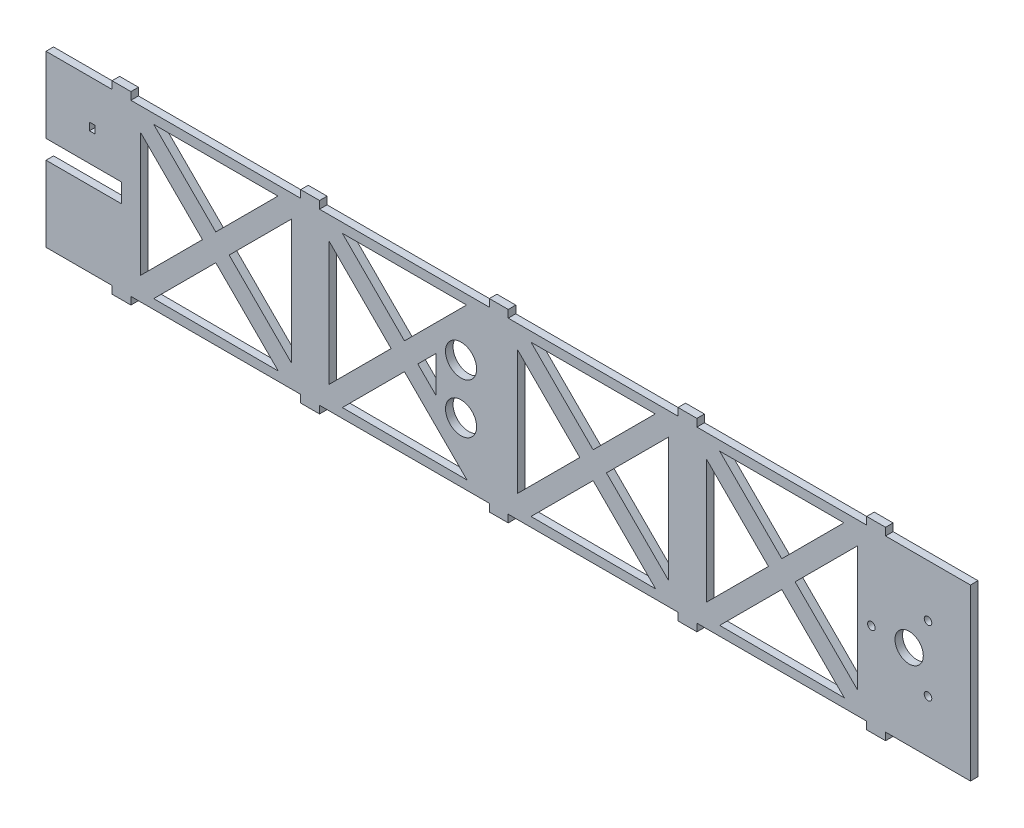
from build123d import *

# Parameters (mm, degrees)
SCHIZZO1_R                   = 7.5
SCHIZZO1_R_2                 = 2
SCHIZZO1_R_3                 = 8.25
SCHIZZO1_W                   = 3
SCHIZZO1_H                   = 4
ESTRUSIONE_ESTRUSIONE1_DEPTH = 4


with BuildPart() as part:
    # Schizzo1 → Estrusione-Estrusione1 (new body)
    with BuildSketch(Plane.XY):
        Polygon((0, 50), (0, 90), (35, 90), (35, 94), (45, 94), (45, 90), (135, 90), (135, 94), (145, 94), (145, 90), (235, 90), (235, 94), (245, 94), (245, 90), (335, 90), (335, 94), (345, 94), (345, 90), (435, 90), (435, 94), (445, 94), (445, 90), (490, 90), (490, 0), (445, 0), (445, -4), (435, -4), (435, 0), (345, 0), (345, -4), (335, -4), (335, 0), (245, 0), (245, -4), (235, -4), (235, 0), (145, 0), (145, -4), (135, -4), (135, 0), (45, 0), (45, -4), (35, -4), (35, 0), (0, 0), (0, 40), (40, 40), (40, 50), align=None)
        with Locations((457.5, 45)):
            Circle(SCHIZZO1_R, mode=Mode.SUBTRACT)
        with Locations((437.5, 45)):
            Circle(SCHIZZO1_R_2, mode=Mode.SUBTRACT)
        with Locations((467.5, 27.679491924)):
            Circle(SCHIZZO1_R_2, mode=Mode.SUBTRACT)
        with Locations((467.5, 62.320508076)):
            Circle(SCHIZZO1_R_2, mode=Mode.SUBTRACT)
        with Locations((220, 58.25)):
            Circle(SCHIZZO1_R_3, mode=Mode.SUBTRACT)
        with Locations((220, 31.75)):
            Circle(SCHIZZO1_R_3, mode=Mode.SUBTRACT)
        Polygon((50, 77.928932188), (50, 12.071067812), (82.928932188, 45), align=None, mode=Mode.SUBTRACT)
        Polygon((130, 77.928932188), (130, 12.071067812), (97.071067812, 45), align=None, mode=Mode.SUBTRACT)
        Polygon((57.071067812, 85), (90, 52.071067812), (122.928932188, 85), align=None, mode=Mode.SUBTRACT)
        Polygon((123.1448388, 4.784093388), (57.077189669, 5.006121857), (90, 37.928932188), align=None, mode=Mode.SUBTRACT)
        Polygon((150, 77.928932188), (150, 12.071067812), (182.928932188, 45), align=None, mode=Mode.SUBTRACT)
        Polygon((157.071067812, 85), (190, 52.071067812), (222.928932188, 85), align=None, mode=Mode.SUBTRACT)
        Polygon((223.1448388, 4.784093388), (157.077189669, 5.006121857), (190, 37.928932188), align=None, mode=Mode.SUBTRACT)
        Polygon((250, 77.928932188), (250, 12.071067812), (282.928932188, 45), align=None, mode=Mode.SUBTRACT)
        Polygon((330, 77.928932188), (330, 12.071067812), (297.071067812, 45), align=None, mode=Mode.SUBTRACT)
        Polygon((257.071067812, 85), (290, 52.071067812), (322.928932188, 85), align=None, mode=Mode.SUBTRACT)
        Polygon((323.1448388, 4.784093388), (257.077189669, 5.006121857), (290, 37.928932188), align=None, mode=Mode.SUBTRACT)
        Polygon((350, 77.928932188), (350, 12.071067812), (382.928932188, 45), align=None, mode=Mode.SUBTRACT)
        Polygon((430, 77.928932188), (430, 12.071067812), (397.071067812, 45), align=None, mode=Mode.SUBTRACT)
        Polygon((357.071067812, 85), (390, 52.071067812), (422.928932188, 85), align=None, mode=Mode.SUBTRACT)
        Polygon((423.1448388, 4.784093388), (357.077189669, 5.006121857), (390, 37.928932188), align=None, mode=Mode.SUBTRACT)
        with Locations((24.5, 67)):
            Rectangle(SCHIZZO1_W, SCHIZZO1_H, mode=Mode.SUBTRACT)
        Polygon((206.75, 54.678932188), (197.071067812, 45), (206.75, 35.321067812), align=None, mode=Mode.SUBTRACT)
    extrude(amount=ESTRUSIONE_ESTRUSIONE1_DEPTH)


solid = part.part
